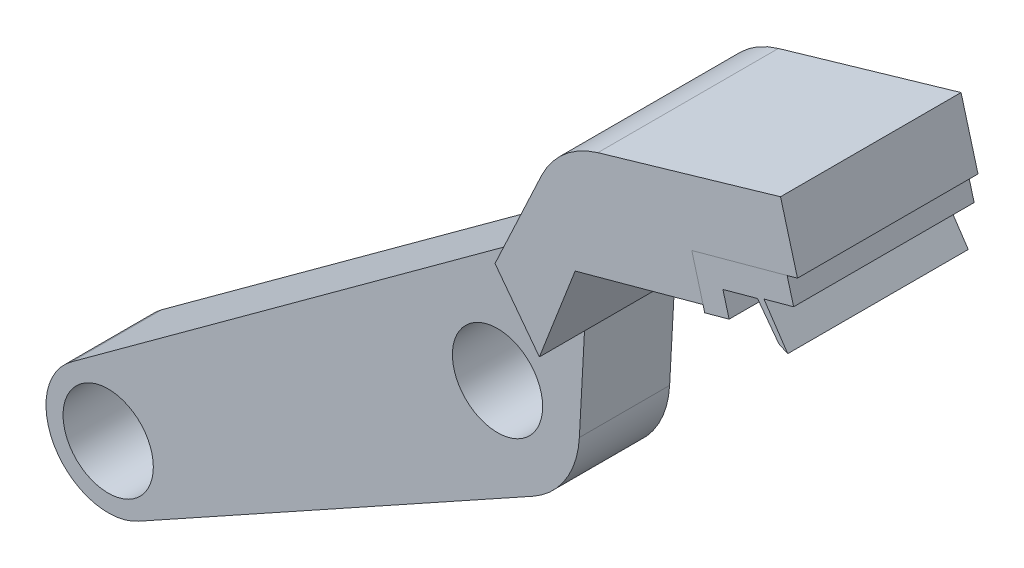
from build123d import *

# Parameters (mm, degrees)
SKETCH_1_R      = 5
EXTRUDE_1_DEPTH = 10
EXTRUDE_2_DEPTH = 10
EXTRUDE_3_DEPTH = 10


with BuildPart() as part:
    # 草图1 → 凸台-拉伸1 (new body)
    with BuildSketch(Plane.XY):
        with BuildLine():
            Line((10.207680571, 20.09846448), (-47.193739247, -21.796773851))
            ThreePointArc((-47.193739247, -21.796773851), (-48.938446672, -31.074098067), (-39.786963622, -33.389936271))
            Line((-39.786963622, -33.389936271), (3.933872673, -9.131154899))
            ThreePointArc((3.933872673, -9.131154899), (7.558896736, -5.692097923), (9.067445715, -0.928465662))
            Line((9.067445715, -0.928465662), (10.207680571, 20.09846448))
        make_face()
        Circle(SKETCH_1_R, mode=Mode.SUBTRACT)
        with Locations((-43.130720056, -27.363589547)):
            Circle(SKETCH_1_R, mode=Mode.SUBTRACT)
    extrude(amount=EXTRUDE_1_DEPTH)

    # 草图2 → 凸台-拉伸2 (add, symmetric)
    with BuildSketch(Plane.XY.offset(5)):
        with BuildLine():
            Line((9.637563143, 9.584999409), (13.60218242, 19.812647766))
            Line((13.60218242, 19.812647766), (27.768612438, 23.680194348))
            Line((27.768612438, 23.680194348), (26.522849943, 28.243295743))
            Line((26.522849943, 28.243295743), (38.23040149, 31.439549204))
            Line((38.23040149, 31.439549204), (36.353581581, 38.314149761))
            Line((36.353581581, 38.314149761), (16.113798559, 32.423466643))
            ThreePointArc((16.113798559, 32.423466643), (12.402880543, 30.416570646), (9.849831601, 27.057927293))
            Line((9.849831601, 27.057927293), (4.723539283, 16.095786375))
            Line((4.723539283, 16.095786375), (9.637563143, 9.584999409))
        make_face()
    extrude(amount=EXTRUDE_2_DEPTH, both=True)


with BuildPart() as body_2:
    # 草图3 → 凸台-拉伸3 (new body, symmetric)
    with BuildSketch(Plane.XY.offset(5)):
        Polygon((27.959492024, 22.981021825), (26.522849943, 28.243295743), (37.083583517, 31.126458896), (37.805217266, 28.483187822), (34.516719177, 27.585402033), (37.150165431, 23.650963909), (36.164364178, 24.114585883), (33.805939355, 27.27930979), (29.972019118, 26.232619475), (30.658560366, 23.717888666), align=None)
    extrude(amount=EXTRUDE_3_DEPTH, both=True)


solid = Compound([part.part, body_2.part])
